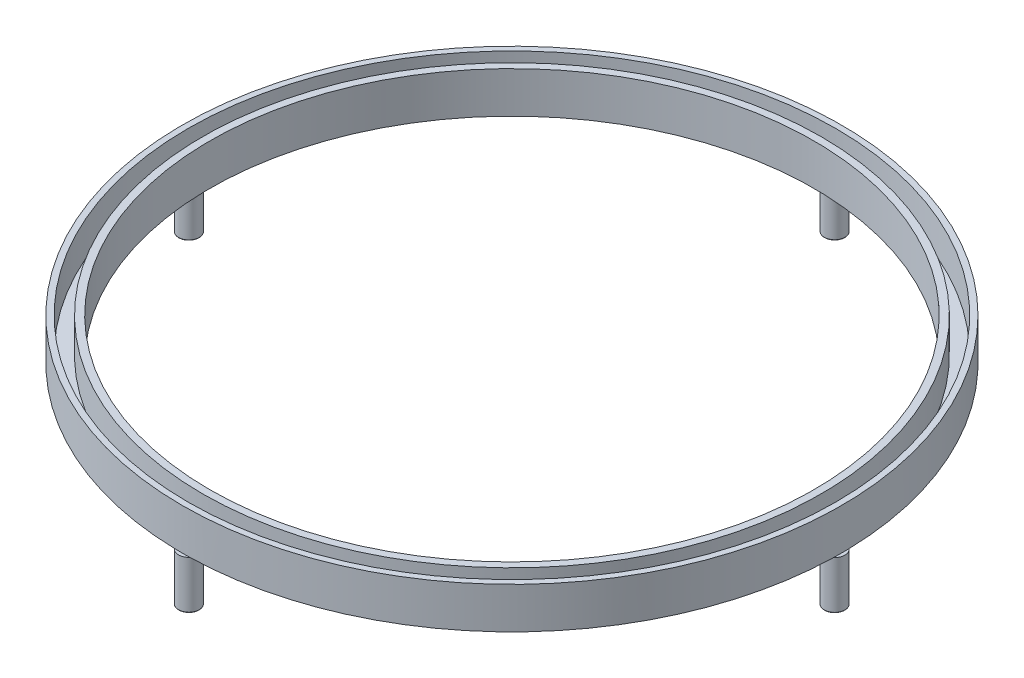
from build123d import *

# Parameters (mm, degrees)
SKETCH1_R           = 48
SKETCH1_R_2         = 44
BOSS_EXTRUDE1_DEPTH = 6
CUT_EXTRUDE3_START  = 1
SKETCH2_R           = 47.15
SKETCH2_R_2         = 45.05
CUT_EXTRUDE3_DEPTH  = 10
SKETCH3_R           = 1.5
BOSS_EXTRUDE2_DEPTH = 7
FILLET1_R           = 0.1


with BuildPart() as part:
    # Sketch1 → Boss-Extrude1 (new body)
    with BuildSketch(Plane(origin=(0, 0, 0), x_dir=(1, 0, 0), z_dir=(0, 1, 0))):
        Circle(SKETCH1_R)
        Circle(SKETCH1_R_2, mode=Mode.SUBTRACT)
    extrude(amount=BOSS_EXTRUDE1_DEPTH)

    # Sketch2 → Cut-Extrude3 (cut)
    with BuildSketch(Plane(origin=(0, 0, 0), x_dir=(1, 0, 0), z_dir=(0, 1, 0)).offset(CUT_EXTRUDE3_START)):
        Circle(SKETCH2_R)
        Circle(SKETCH2_R_2, mode=Mode.SUBTRACT)
    extrude(amount=CUT_EXTRUDE3_DEPTH, mode=Mode.SUBTRACT)

    # Sketch3 → Boss-Extrude2 (add)
    with BuildSketch(Plane(origin=(0, 0, 0), x_dir=(1, 0, 0), z_dir=(0, 1, 0))):
        with Locations((0, 47)):
            Circle(SKETCH3_R)
        with Locations((47, 0)):
            Circle(SKETCH3_R)
        with Locations((-0.045212766, -46.999978253)):
            Circle(SKETCH3_R)
        with Locations((-46.999978253, -0.045212766)):
            Circle(SKETCH3_R)
    extrude(amount=-BOSS_EXTRUDE2_DEPTH)

    # Fillet1
    fillet1_edges = [part.edges().sort_by_distance(p)[0] for p in [
        (-1.5, -7, -47),
        (45.5, -7, 0),
        (-1.545212766, -7, 46.999978253),
        (-48.499978253, -7, 0.045212766),
    ]]
    fillet(fillet1_edges, radius=FILLET1_R)


solid = part.part
